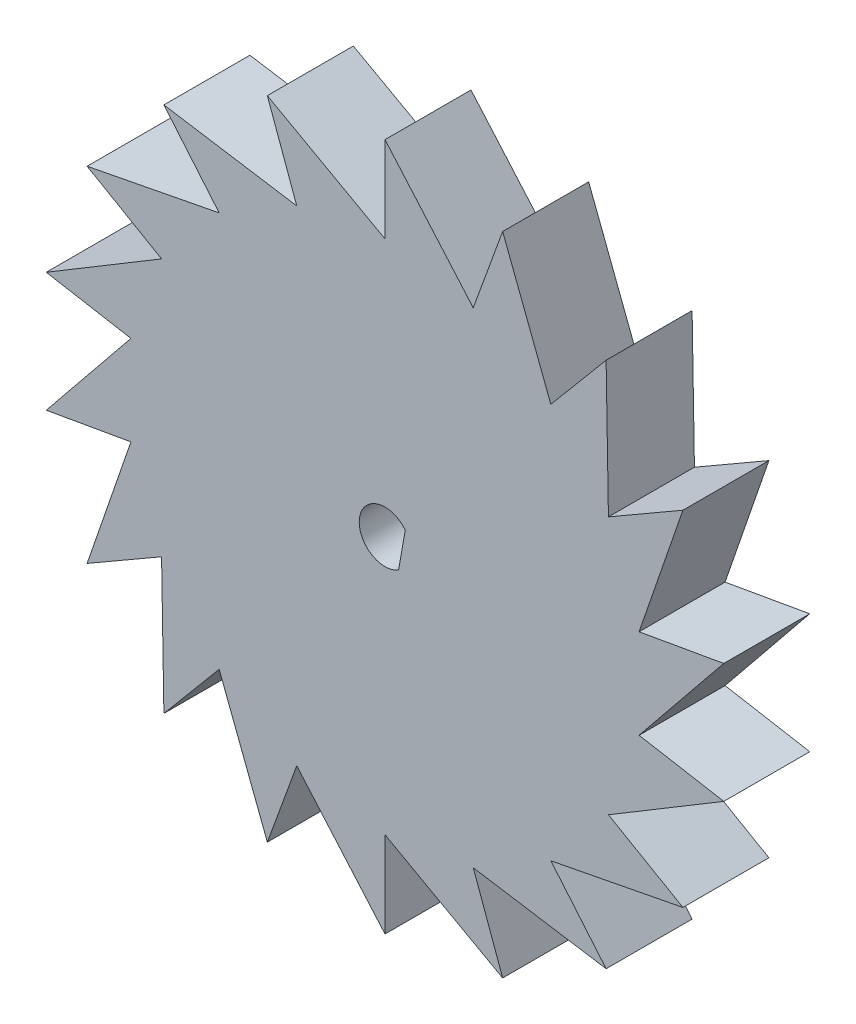
from build123d import *

# Parameters (mm, degrees)
BOSS_EXTRUDE1_DEPTH = 5
CIRPATTERN1_COUNT   = 18
SKETCH7_R           = 4
BOSS_EXTRUDE3_DEPTH = 5
CUT_EXTRUDE1_DEPTH  = 10


with BuildPart() as part:
    # Sketch1 → Boss-Extrude1 (new body)
    with BuildSketch(Plane.XY):
        Polygon((0, 0), (0, 20), (5.13030215, 14.095389312), align=None)
    boss_extrude1 = extrude(amount=BOSS_EXTRUDE1_DEPTH)

    # CirPattern1: Boss-Extrude1 ×18 about axis
    cirpattern1_axis = Axis((0, 0, 0), (0, 0, 1))
    for i in range(1, CIRPATTERN1_COUNT):
        add(boss_extrude1.rotate(cirpattern1_axis, i * 360 / CIRPATTERN1_COUNT))

    # Sketch7 → Boss-Extrude3 (add)
    with BuildSketch(Plane(origin=(0, 0, 0), x_dir=(-1, 0, 0), z_dir=(0, 0, -1))):
        Circle(SKETCH7_R)
    extrude(amount=BOSS_EXTRUDE3_DEPTH)

    # Sketch5 → Cut-Extrude1 (cut)
    with BuildSketch(Plane.XY.offset(5)):
        with BuildLine():
            Line((1.17901122, 0.927325479), (0.790582224, -1.274746935))
            ThreePointArc((0.790582224, -1.274746935), (-1.477195083, 0.260566092), (1.17901122, 0.927325479))
        make_face()
    extrude(amount=-CUT_EXTRUDE1_DEPTH, mode=Mode.SUBTRACT)


solid = part.part
